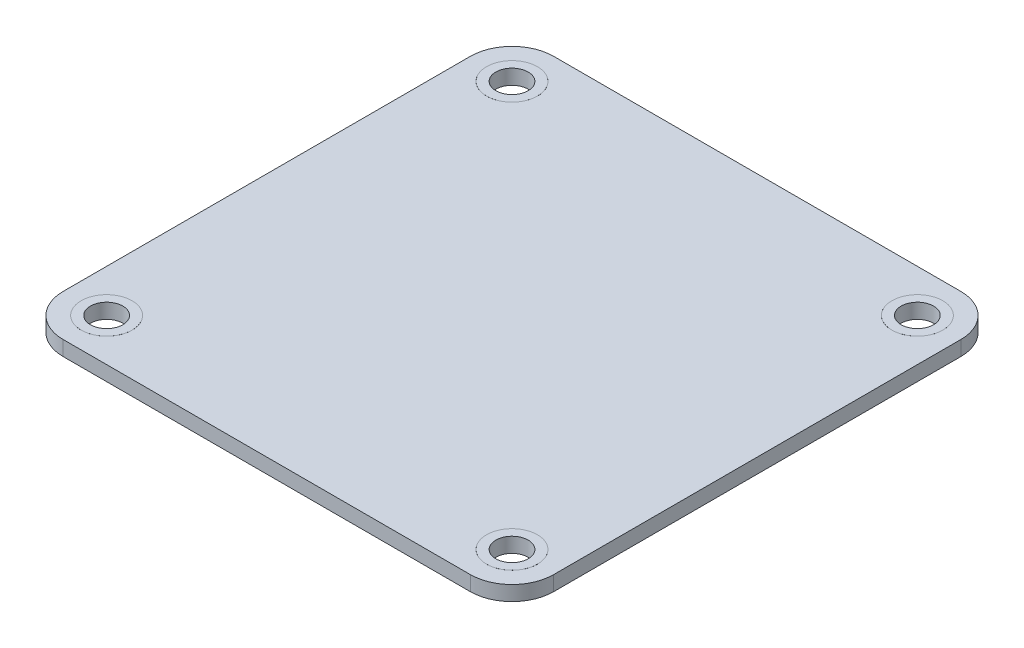
from build123d import *

# Parameters (mm, degrees)
SKETCH1_R           = 1.755
BOSS_EXTRUDE1_DEPTH = 1.6
BOSS_EXTRUDE2_START = 0.8
SKETCH2_R           = 2.75
SKETCH2_R_2         = 1.75
BOSS_EXTRUDE2_DEPTH = 0.805


with BuildPart() as part:
    # Sketch1 → Boss-Extrude1 (new body)
    with BuildSketch(Plane(origin=(0, 0, 0), x_dir=(1, 0, 0), z_dir=(0, 1, 0))):
        with BuildLine():
            Line((22, -26.5), (-22, -26.5))
            ThreePointArc((-22, -26.5), (-25.181980515, -25.181980515), (-26.5, -22))
            Line((-26.5, -22), (-26.5, 22))
            ThreePointArc((-26.5, 22), (-25.181980515, 25.181980515), (-22, 26.5))
            Line((-22, 26.5), (22, 26.5))
            ThreePointArc((22, 26.5), (25.181980515, 25.181980515), (26.5, 22))
            Line((26.5, 22), (26.5, -22))
            ThreePointArc((26.5, -22), (25.181980515, -25.181980515), (22, -26.5))
        make_face()
        with Locations((-21.9, 21.9)):
            Circle(SKETCH1_R, mode=Mode.SUBTRACT)
        with Locations((21.9, 21.9)):
            Circle(SKETCH1_R, mode=Mode.SUBTRACT)
        with Locations((-21.9, -21.9)):
            Circle(SKETCH1_R, mode=Mode.SUBTRACT)
        with Locations((21.9, -21.9)):
            Circle(SKETCH1_R, mode=Mode.SUBTRACT)
    extrude(amount=BOSS_EXTRUDE1_DEPTH)

    # Sketch2 → Boss-Extrude2 (add, symmetric)
    with BuildSketch(Plane(origin=(0, 0, 0), x_dir=(1, 0, 0), z_dir=(0, 1, 0)).offset(BOSS_EXTRUDE2_START)):
        with Locations((-21.9, 21.9)):
            Circle(SKETCH2_R)
        with Locations((-21.9, 21.9)):
            Circle(SKETCH2_R_2, mode=Mode.SUBTRACT)
        with Locations((21.9, 21.9)):
            Circle(SKETCH2_R)
        with Locations((21.9, 21.9)):
            Circle(SKETCH2_R_2, mode=Mode.SUBTRACT)
        with Locations((21.9, -21.9)):
            Circle(SKETCH2_R)
        with Locations((21.9, -21.9)):
            Circle(SKETCH2_R_2, mode=Mode.SUBTRACT)
        with Locations((-21.9, -21.9)):
            Circle(SKETCH2_R)
        with Locations((-21.9, -21.9)):
            Circle(SKETCH2_R_2, mode=Mode.SUBTRACT)
    extrude(amount=BOSS_EXTRUDE2_DEPTH, both=True)


solid = part.part
